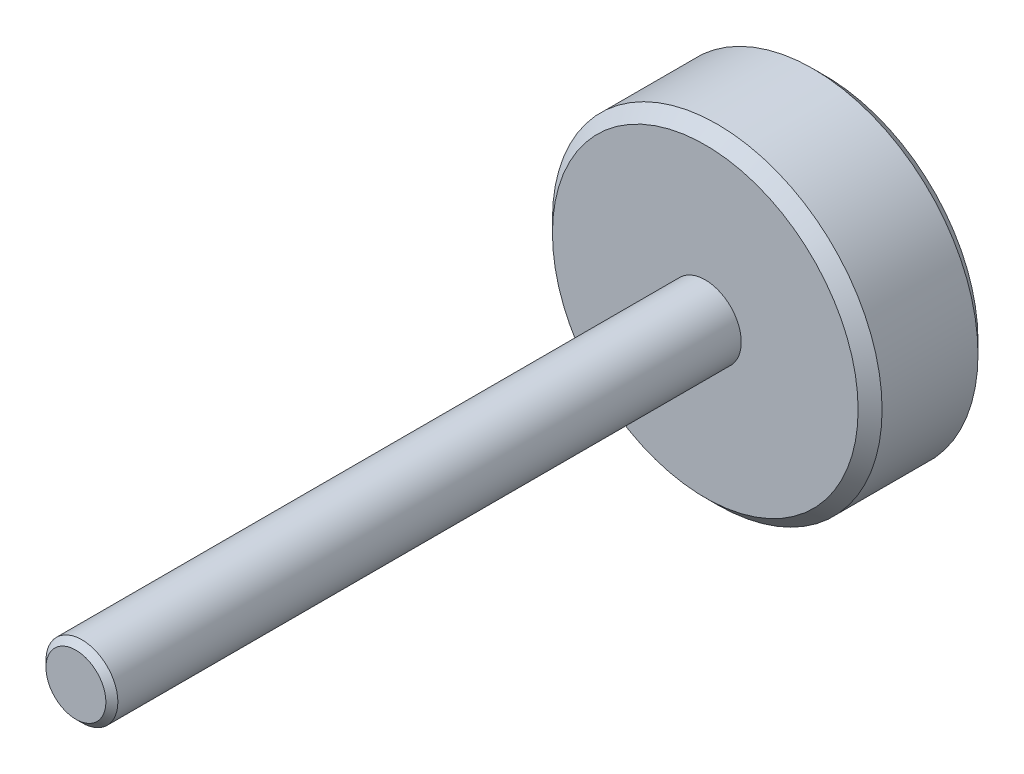
from build123d import *

# Parameters (mm, degrees)
SKETCH1_R           = 27.5
BOSS_EXTRUDE1_DEPTH = 20
SKETCH2_R           = 6
BOSS_EXTRUDE2_DEPTH = 105
CHAMFER1_SIZE       = 1
CHAMFER2_SIZE       = 2


with BuildPart() as part:
    # Sketch1 → Boss-Extrude1 (new body)
    with BuildSketch(Plane.XY):
        Circle(SKETCH1_R)
    extrude(amount=BOSS_EXTRUDE1_DEPTH)

    # Sketch2 → Boss-Extrude2 (add)
    with BuildSketch(Plane.XY.offset(20)):
        Circle(SKETCH2_R)
    extrude(amount=BOSS_EXTRUDE2_DEPTH)

    # Chamfer1
    chamfer1_edges = [part.edges().sort_by_distance(p)[0] for p in [
        (-6, 0, 125),
    ]]
    chamfer(chamfer1_edges, length=CHAMFER1_SIZE)

    # Chamfer2
    chamfer2_edges = [part.edges().sort_by_distance(p)[0] for p in [
        (-27.5, 0, 0),
        (-27.5, 0, 20),
    ]]
    chamfer(chamfer2_edges, length=CHAMFER2_SIZE)


solid = part.part
